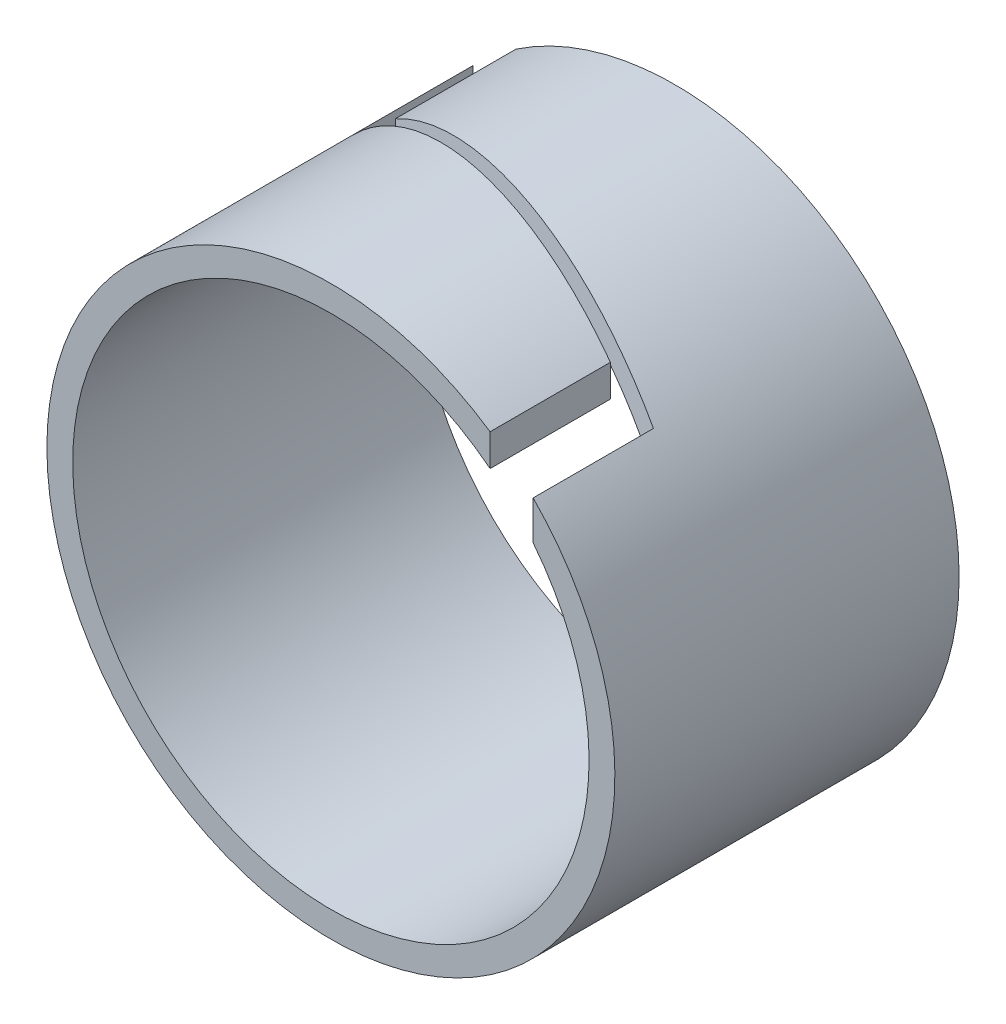
from build123d import *

# Parameters (mm, degrees)
SKETCH2_R           = 3.3
SKETCH2_R_2         = 3
BOSS_EXTRUDE1_DEPTH = 4
CUT_EXTRUDE1_DEPTH  = 5


with BuildPart() as part:
    # Sketch2 → Boss-Extrude1 (new body)
    with BuildSketch(Plane.XY):
        Circle(SKETCH2_R)
        Circle(SKETCH2_R_2, mode=Mode.SUBTRACT)
    extrude(amount=BOSS_EXTRUDE1_DEPTH)

    # Sketch3 → Cut-Extrude1 (cut)
    with BuildSketch(Plane(origin=(0, 3.3, 0), x_dir=(1, 0, 0), z_dir=(0, 1, 0))):
        Polygon((1.85, -4), (2.35, -4), (2.35, -2.60176001), (-1.85, -1.4), (-1.85, 0), (-2.35, 0), (-2.35, -1.4), (1.85, -2.60176001), align=None)
    extrude(amount=-CUT_EXTRUDE1_DEPTH, mode=Mode.SUBTRACT)


solid = part.part
